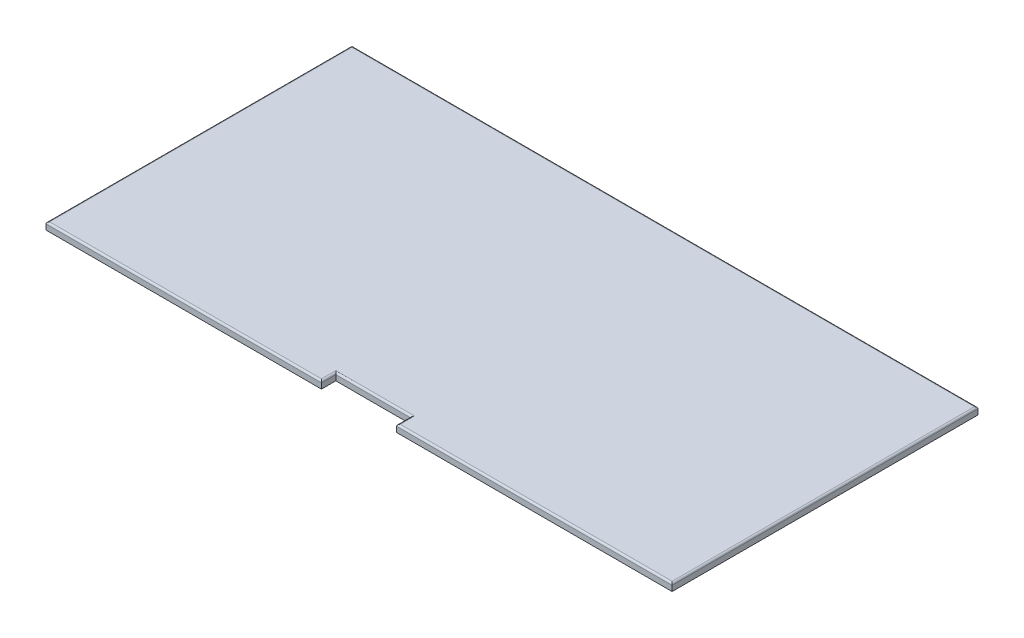
from build123d import *

# Parameters (mm, degrees)
SKETCH1_W           = 1750
SKETCH1_H           = 855
BOSS_EXTRUDE1_DEPTH = 20
SKETCH2_W           = 210
SKETCH2_H           = 80
CUT_EXTRUDE1_DEPTH  = 20
FILLET1_R           = 5


with BuildPart() as part:
    # Sketch1 → Boss-Extrude1 (new body)
    with BuildSketch(Plane(origin=(0, 0, 0), x_dir=(1, 0, 0), z_dir=(0, 1, 0))):
        Rectangle(SKETCH1_W, SKETCH1_H)
    extrude(amount=BOSS_EXTRUDE1_DEPTH)

    # Sketch2 → Cut-Extrude1 (cut)
    with BuildSketch(Plane(origin=(0, 20, 0), x_dir=(1, 0, 0), z_dir=(0, 1, 0))):
        with Locations((0, -427.5)):
            Rectangle(SKETCH2_W, SKETCH2_H)
    extrude(amount=-CUT_EXTRUDE1_DEPTH, mode=Mode.SUBTRACT)

    # Fillet1
    fillet1_edges = [part.edges().sort_by_distance(p)[0] for p in [
        (-875, 20, 0),
        (490, 20, 427.5),
        (-490, 20, 427.5),
        (-105, 20, 407.5),
        (105, 20, 407.5),
        (0, 20, 387.5),
        (875, 20, 0),
        (0, 20, -427.5),
    ]]
    fillet(fillet1_edges, radius=FILLET1_R)


solid = part.part
